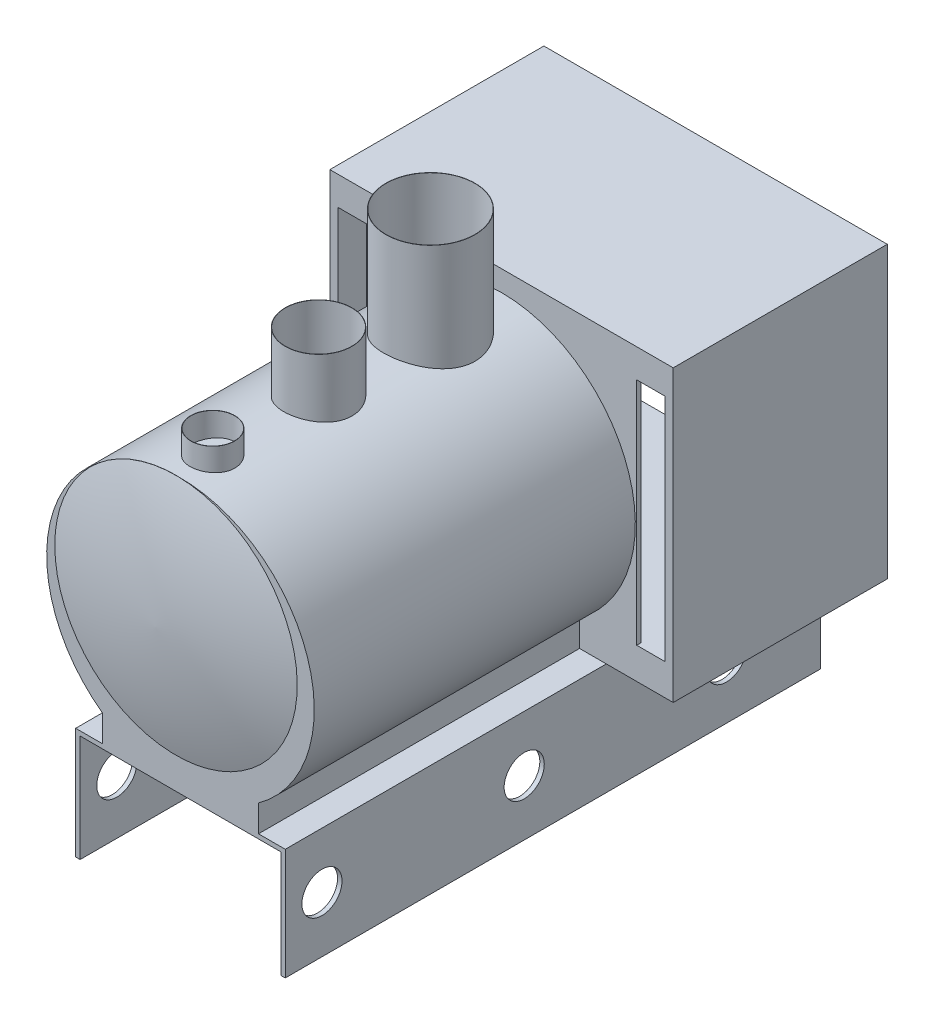
from build123d import *

# Parameters (mm, degrees)
BOSS_EXTRUDE3_DEPTH     = 3657.6
SKETCH2_W               = 320
SKETCH2_H               = 2618.714829249
BOSS_EXTRUDE4_DEPTH     = 2438.4
SKETCH4_W               = 3080.33
SKETCH4_H               = 2618.714829249
CUT_EXTRUDE1_DEPTH      = 2387.6
SKETCH5_R               = 228.6
CUT_EXTRUDE2_DEPTH      = 2115.312
CUT_EXTRUDE2_DEPTH_BACK = 4484.116
SKETCH9_W               = 2.54
SKETCH9_H               = 970.788
SKETCH10_W              = 2.54
SKETCH10_H              = 1156.208
SKETCH11_W              = 2.54
SKETCH11_H              = 1727.2


with BuildPart() as part:
    # Sketch1 → Boss-Extrude3 (new body)
    with BuildSketch(Plane.XY):
        with BuildLine():
            Line((-50.8, 0), (0, 0))
            Line((0, 0), (0, 1270))
            Line((0, 1270), (-304.8, 1270))
            Line((-304.8, 1270), (-304.8, 1574.8))
            ThreePointArc((-304.8, 1574.8), (-1193.8, 4336.642881791), (-2082.8, 1574.8))
            Line((-2082.8, 1574.8), (-2082.8, 1270))
            Line((-2082.8, 1270), (-2387.6, 1270))
            Line((-2387.6, 1270), (-2387.6, 0))
            Line((-2387.6, 0), (-2336.8, 0))
            Line((-2336.8, 0), (-2336.8, 1219.2))
            Line((-2336.8, 1219.2), (-50.8, 1219.2))
            Line((-50.8, 1219.2), (-50.8, 0))
        make_face()
    extrude(amount=-BOSS_EXTRUDE3_DEPTH)

    # Sketch2 → Boss-Extrude4 (add)
    with BuildSketch(Plane(origin=(0, 0, -3657.6), x_dir=(-1, 0, 0), z_dir=(0, 0, -1))):
        Polygon((0, 1270), (0, 0), (50.8, 0), (50.8, 1219.2), (2336.8, 1219.2), (2336.8, 0), (2387.6, 0), (2387.6, 1270), (3149.6, 1270), (3149.6, 4572), (-762, 4572), (-762, 1270), align=None)
        with Locations((-506.365, 2936.339064801)):
            Rectangle(SKETCH2_W, SKETCH2_H, mode=Mode.SUBTRACT)
        with Locations((2893.965, 2936.339064801)):
            Rectangle(SKETCH2_W, SKETCH2_H, mode=Mode.SUBTRACT)
    extrude(amount=BOSS_EXTRUDE4_DEPTH)

    # Sketch4 → Cut-Extrude1 (cut)
    with BuildSketch(Plane(origin=(0, 0, -6096), x_dir=(-1, 0, 0), z_dir=(0, 0, -1))):
        with Locations((1193.8, 2936.339064801)):
            Rectangle(SKETCH4_W, SKETCH4_H)
    extrude(amount=-CUT_EXTRUDE1_DEPTH, mode=Mode.SUBTRACT)

    # Sketch5 → Cut-Extrude2 (cut, two sides)
    with BuildSketch(Plane(origin=(0, 0, 0), x_dir=(0, 0, -1), z_dir=(1, 0, 0))) as cut_extrude2_sk:
        with Locations(Location((5026.057168607, 635, 0), (0, 0, 270))):
            Circle(SKETCH5_R)
        with Locations(Location((2722.057168607, 635, 0), (0, 0, 270))):
            Circle(SKETCH5_R)
        with Locations(Location((418.057168607, 635, 0), (0, 0, 270))):
            Circle(SKETCH5_R)
    extrude(amount=CUT_EXTRUDE2_DEPTH, mode=Mode.SUBTRACT)
    extrude(cut_extrude2_sk.sketch, amount=-CUT_EXTRUDE2_DEPTH_BACK, mode=Mode.SUBTRACT)

    # Sketch9 → Revolve-Thin2 (revolve)
    with BuildSketch(Plane.ZY.offset(1244.6), mode=Mode.PRIVATE) as revolve_thin2_sk:
        with Locations((-668.487238084, 4106.373777006)):
            Rectangle(SKETCH9_W, SKETCH9_H)
    revolve(revolve_thin2_sk.sketch.rotate(Axis((-1244.6, 4552.900640391, -418.748581478), (0, -1, 0)), 180), axis=Axis((-1244.6, 4552.900640391, -418.748581478), (0, -1, 0)))

    # Sketch10 → Revolve-Thin3 (revolve)
    with BuildSketch(Plane.ZY.offset(1244.6)):
        with Locations((-1244.352427091, 4409.367926067)):
            Rectangle(SKETCH10_W, SKETCH10_H)
    revolve(axis=Axis((-1244.6, 4987.471926067, -1624.082427091), (0, -1, 0)))

    # Sketch11 → Revolve-Thin4 (revolve)
    with BuildSketch(Plane.ZY.offset(1244.6)):
        with Locations((-2391.909754716, 4652.235687928)):
            Rectangle(SKETCH11_W, SKETCH11_H)
    revolve(axis=Axis((-1244.6, 5515.835687928, -2898.639754716), (0, -1, 0)))

    # Sketch13 → Revolve-Thin5 (revolve)
    with BuildSketch(Plane.ZY.offset(1244.6), mode=Mode.PRIVATE) as revolve_thin5_sk:
        with BuildLine():
            Line((0, 2955.721440895), (231.899056111, 2955.721440895))
            ThreePointArc((231.899056111, 2955.721440895), (165.131589664, 3654.441337663), (0, 4336.642881791))
            Line((0, 4336.642881791), (-2.420009973, 4335.871421012))
            ThreePointArc((-2.420009973, 4335.871421012), (162.411023884, 3655.303753365), (229.296258404, 2958.261440895))
            Line((229.296258404, 2958.261440895), (0, 2958.261440895))
            Line((0, 2958.261440895), (0, 2955.721440895))
        make_face()
    revolve(revolve_thin5_sk.sketch.rotate(Axis((-1244.6, 2955.721440895, 0), (0, 0, 1)), 90), axis=Axis((-1244.6, 2955.721440895, 0), (0, 0, 1)))


solid = part.part
